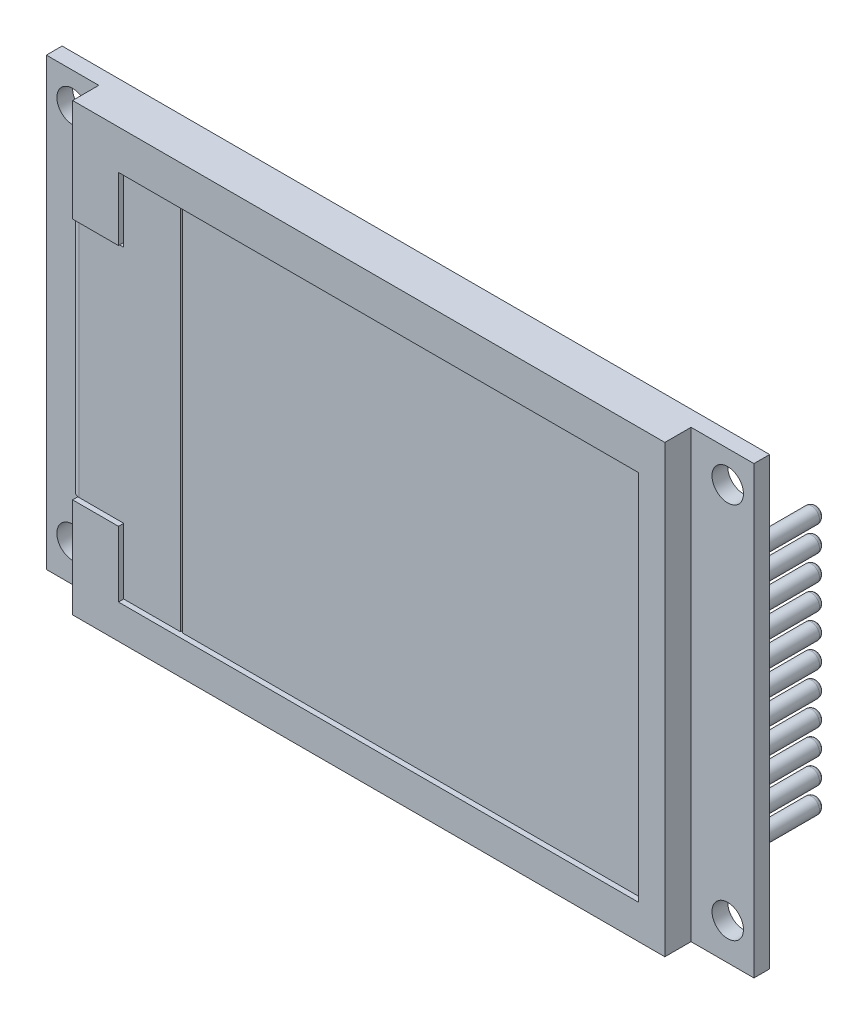
from build123d import *

# Parameters (mm, degrees)
SKIZZE1_W                            = 67.5
SKIZZE1_H                            = 42.5
AUFSATZ_LINEAR_AUSTRAGEN1_DEPTH      = 1.5
SKIZZE2_W                            = 56.5
SKIZZE2_H                            = 42.5
AUFSATZ_LINEAR_AUSTRAGEN2_DEPTH      = 2.5
SKIZZE3_R                            = 1.5
SCHNITT_LINEAR_AUSTRAGEN1_DEPTH      = 2.5
LINEARES_MUSTER1_COUNT               = 2
LINEARES_MUSTER1_PITCH               = 62.5
AUFSATZ_LINEAR_AUSTRAGEN3_DEPTH      = 3
SKIZZE5_W                            = 44
SKIZZE5_H                            = 35.5
SCHNITT_LINEAR_AUSTRAGEN2_DEPTH      = 0.5
SCHNITT_LINEAR_AUSTRAGEN3_DEPTH      = 0.9
AUFSATZ_LINEAR_AUSTRAGEN4_DEPTH      = 0.6
AUFSATZ_LINEAR_AUSTRAGEN4_DEPTH_BACK = 1.6
VERRUNDUNG6_R                        = 0.8
SKIZZE8_W                            = 25
SKIZZE8_H                            = 2
SCHNITT_LINEAR_AUSTRAGEN4_DEPTH      = 9.56
SKIZZE9_W                            = 3
SKIZZE9_H                            = 27.5
AUFSATZ_LINEAR_AUSTRAGEN5_DEPTH      = 1
SKIZZE10_R                           = 0.75
AUFSATZ_LINEAR_AUSTRAGEN6_DEPTH      = 6
VERRUNDUNG18_R                       = 0.5


with BuildPart() as part:
    # Skizze1 → Aufsatz-Linear austragen1 (new body)
    with BuildSketch(Plane.XY):
        Rectangle(SKIZZE1_W, SKIZZE1_H)
    extrude(amount=AUFSATZ_LINEAR_AUSTRAGEN1_DEPTH)

    # Skizze3 → Schnitt-Linear austragen1 (cut, through all)
    with BuildSketch(Plane.XY.offset(1.5)):
        with Locations((-31.25, -17.75)):
            Circle(SKIZZE3_R)
        with Locations((-31.25, 18.25)):
            Circle(SKIZZE3_R)
    schnitt_linear_austragen1 = extrude(amount=-SCHNITT_LINEAR_AUSTRAGEN1_DEPTH, mode=Mode.SUBTRACT)

    # Lineares Muster1: Schnitt-Linear austragen1 ×2
    with Locations(*[(i * LINEARES_MUSTER1_PITCH, 0, 0) for i in range(1, LINEARES_MUSTER1_COUNT)]):
        add(schnitt_linear_austragen1, mode=Mode.SUBTRACT)



with BuildPart() as body_2:
    # Skizze2 → Aufsatz-Linear austragen2 (new body)
    with BuildSketch(Plane.XY.offset(1.5)):
        with Locations((-0.5, 0)):
            Rectangle(SKIZZE2_W, SKIZZE2_H)
    extrude(amount=AUFSATZ_LINEAR_AUSTRAGEN2_DEPTH)

    # Skizze5 → Schnitt-Linear austragen2 (cut)
    with BuildSketch(Plane.XY.offset(4)):
        with Locations((3.25, -0.25)):
            Rectangle(SKIZZE5_W, SKIZZE5_H)
    extrude(amount=-SCHNITT_LINEAR_AUSTRAGEN2_DEPTH, mode=Mode.SUBTRACT)

    # Skizze6 → Schnitt-Linear austragen3 (cut)
    with BuildSketch(Plane.XY.offset(4)):
        Polygon((-18.75, 17.5), (-24.375332321, 17.5), (-24.375332321, 11.451186515), (-28.75, 11.451186515), (-28.75, -11.744953417), (-24.375332321, -11.744953417), (-24.375332321, -18), (-18.75, -18), align=None)
    extrude(amount=-SCHNITT_LINEAR_AUSTRAGEN3_DEPTH, mode=Mode.SUBTRACT)


with BuildPart() as body_3:
    # Skizze4 → Aufsatz-Linear austragen3 (new body)
    with BuildSketch(Plane(origin=(0, 0, 0), x_dir=(-1, 0, 0), z_dir=(0, 0, -1))):
        Polygon((18.75, -21.25), (18.75, -11.25), (15.75, -9.25), (15.75, -4.25), (-7.25, -4.25), (-7.25, -21.25), align=None)
    extrude(amount=AUFSATZ_LINEAR_AUSTRAGEN3_DEPTH)

    # Skizze8 → Schnitt-Linear austragen4 (cut)
    with BuildSketch(Plane.XZ.offset(21.25)):
        with Locations((-5.75, -1.5)):
            Rectangle(SKIZZE8_W, SKIZZE8_H)
    extrude(amount=-SCHNITT_LINEAR_AUSTRAGEN4_DEPTH, mode=Mode.SUBTRACT)


with BuildPart() as part_1:
    add(part.part)

    add(body_2.part)  # Aufsatz-Linear austragen4 merges body 2
    # Skizze7 → Aufsatz-Linear austragen4 (add, two sides)
    with BuildSketch(Plane.XY.offset(3.1)) as aufsatz_linear_austragen4_sk:
        Polygon((-18.75, 17.3), (-24.175332321, 17.3), (-24.175332321, 11.251186515), (-29.25, 11.251186515), (-29.25, -11.544953417), (-24.175332321, -11.544953417), (-24.175332321, -17.8), (-18.75, -17.8), align=None)
    extrude(amount=AUFSATZ_LINEAR_AUSTRAGEN4_DEPTH)
    extrude(aufsatz_linear_austragen4_sk.sketch, amount=-AUFSATZ_LINEAR_AUSTRAGEN4_DEPTH_BACK)

    # Verrundung6
    verrundung6_edges = [part_1.edges().sort_by_distance(p)[0] for p in [
        (-29.25, -0.146883451, 3.7),
    ]]
    fillet(verrundung6_edges, radius=VERRUNDUNG6_R)

    # Skizze9 → Aufsatz-Linear austragen5 (add)
    with BuildSketch(Plane(origin=(0, 0, 0), x_dir=(-1, 0, 0), z_dir=(0, 0, -1))):
        with Locations((-31.25, 0)):
            Rectangle(SKIZZE9_W, SKIZZE9_H)
    extrude(amount=AUFSATZ_LINEAR_AUSTRAGEN5_DEPTH)

    # Skizze10 → Aufsatz-Linear austragen6 (add)
    with BuildSketch(Plane(origin=(0, 0, -1), x_dir=(-1, 0, 0), z_dir=(0, 0, -1))):
        with Locations((-31.25, -12.25)):
            Circle(SKIZZE10_R)
        with Locations((-31.25, -9.85)):
            Circle(SKIZZE10_R)
        with Locations((-31.25, -7.45)):
            Circle(SKIZZE10_R)
        with Locations((-31.25, -5.05)):
            Circle(SKIZZE10_R)
        with Locations((-31.25, -2.65)):
            Circle(SKIZZE10_R)
        with Locations((-31.25, -0.25)):
            Circle(SKIZZE10_R)
        with Locations((-31.25, 2.15)):
            Circle(SKIZZE10_R)
        with Locations((-31.25, 4.55)):
            Circle(SKIZZE10_R)
        with Locations((-31.25, 6.95)):
            Circle(SKIZZE10_R)
        with Locations((-31.25, 9.35)):
            Circle(SKIZZE10_R)
        with Locations((-31.25, 11.75)):
            Circle(SKIZZE10_R)
    extrude(amount=AUFSATZ_LINEAR_AUSTRAGEN6_DEPTH)

    # Verrundung18
    verrundung18_edges = [part_1.edges().sort_by_distance(p)[0] for p in [
        (32, -12.25, -7),
        (32, -9.85, -7),
        (32, -7.45, -7),
        (32, -5.05, -7),
        (32, -2.65, -7),
        (32, -0.25, -7),
        (32, 2.15, -7),
        (32, 4.55, -7),
        (32, 6.95, -7),
        (32, 9.35, -7),
        (32, 11.75, -7),
    ]]
    fillet(verrundung18_edges, radius=VERRUNDUNG18_R)


solid = Compound([body_3.part, part_1.part])
